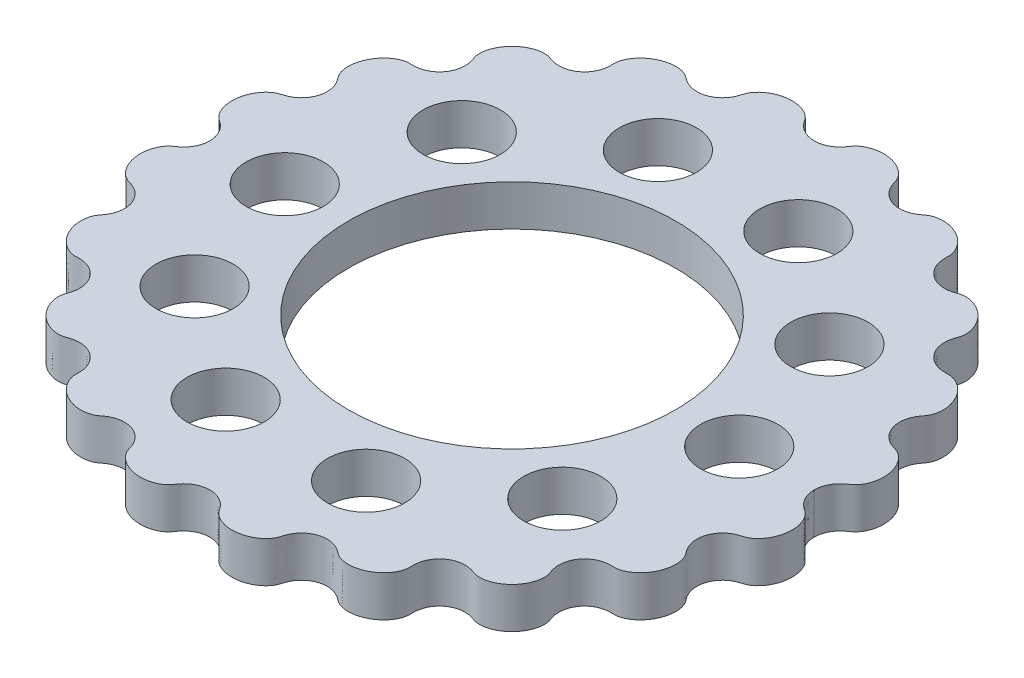
from build123d import *

# Parameters (mm, degrees)
SKETCH1_R           = 36
SKETCH1_R_2         = 8.5
BOSS_EXTRUDE1_DEPTH = 9


with BuildPart() as part:
    # Sketch1 → Boss-Extrude1 (new body)
    with BuildSketch(Plane(origin=(0, 0, 0), x_dir=(1, 0, 0), z_dir=(0, 1, 0))):
        with BuildLine():
            add(Edge.make_bspline(
                [(66.500001129, 0), (66.500001058, -0.306411604), (66.541874966, -0.881988973), (66.71785149, -1.70970182), (67.122305388, -2.64485153), (67.601319233, -3.385898988), (68.073478895, -3.930767497), (68.484626923, -4.318373717), (68.876385974, -4.631660775), (69.233666052, -4.885778583), (69.564274067, -5.103618664), (69.843214443, -5.321468288), (70.117872249, -5.581732221), (70.400827867, -5.901729461), (70.702289774, -6.32382216), (71.054596033, -6.952661744), (71.375662814, -7.747169294), (71.615376495, -8.685667354), (71.731212347, -9.758967821), (71.701410518, -10.823240788), (71.536133006, -11.860141355), (71.244225804, -12.853472523), (70.833511924, -13.788305192), (70.358839298, -14.56570152), (69.8607071, -15.191593009), (69.385303473, -15.666161002), (68.964677629, -16.012242392), (68.548124551, -16.287014605), (68.188697639, -16.471846169), (67.885284263, -16.5894738), (67.6026674, -16.678972685), (67.317739076, -16.760519952), (66.914744907, -16.885104266), (66.402737123, -17.07994391), (65.770956105, -17.391405185), (65.047003925, -17.880225456), (64.353873132, -18.533266519), (63.737773446, -19.372683616), (63.275037833, -20.335343374), (63.000837701, -21.369915681), (62.928927044, -22.453502681), (63.052813163, -23.427940267), (63.297757861, -24.251137315), (63.587039056, -24.893246766), (63.860894636, -25.371811104), (64.145161772, -25.790016395), (64.425506551, -26.15372471), (64.719695703, -26.532707796), (64.965405483, -26.968707897), (65.16448089, -27.455245279), (65.315337371, -27.986150519), (65.436916585, -28.660703608), (65.486679126, -29.479710966), (65.421096201, -30.426005667), (65.195898518, -31.477846281), (64.833514294, -32.48361594), (64.345892961, -33.427772857), (63.74361321, -34.29551734), (63.03639755, -35.071911975), (62.319416122, -35.667562159), (61.632614436, -36.102896779), (61.018606487, -36.397527171), (60.501368956, -36.585067331), (60.002736898, -36.705605486), (59.582782992, -36.754609123), (59.238659914, -36.75517943), (58.919479065, -36.745458109), (58.600187888, -36.737961835), (58.186622973, -36.744933326), (57.680555248, -36.788795144), (57.025772755, -36.903424808), (56.231100187, -37.148620477), (55.38015461, -37.568193877), (54.524775544, -38.212860592), (53.798856727, -39.016244684), (53.245744288, -39.931413343), (52.876403424, -40.932154541), (52.712876934, -41.903813432), (52.711126431, -42.801048358), (52.815319507, -43.527425125), (52.941387719, -44.03315486), (53.055590073, -44.395960805), (53.149312539, -44.668429567), (53.247939565, -44.939017776), (53.364965435, -45.291387725), (53.452192412, -45.737703364), (53.491958948, -46.257673299), (53.468644886, -46.845886624), (53.363394796, -47.556426753), (53.136734845, -48.374484506), (52.768362447, -49.246519483), (52.234936332, -50.143673486), (51.583820614, -50.970470183), (50.825006742, -51.712551368), (49.978560672, -52.346849878), (49.058219136, -52.860671942), (48.200835241, -53.193586977), (47.439728455, -53.383993333), (46.783575506, -53.471154427), (46.24340017, -53.490536996), (45.735563964, -53.453013161), (45.317452545, -53.369908695), (44.99172708, -53.265499715), (44.699608393, -53.161002724), (44.407046103, -53.057647945), (44.006263137, -52.932952789), (43.490986386, -52.811450496), (42.800133999, -52.714477617), (41.927158988, -52.709986829), (40.953037619, -52.8674568), (39.920202857, -53.248889007), (38.974122337, -53.827688413), (38.169054018, -54.570301693), (37.529920825, -55.442926772), (37.101897331, -56.344011596), (36.879347754, -57.124787466), (36.780264942, -57.759487878), (36.745430562, -58.228868202), (36.738116129, -58.595650957), (36.745630266, -58.954274161), (36.758794675, -59.304761433), (36.745284462, -59.70007659), (36.677901942, -60.135221923), (36.549281488, -60.614594814), (36.349127337, -61.129714855), (36.040546931, -61.740807466), (35.589726474, -62.423279282), (34.976854855, -63.134572527), (34.181164504, -63.833500102), (33.295605947, -64.424159937), (32.335438574, -64.896819614), (31.315952582, -65.240823512), (30.253281677, -65.444073282), (29.302808186, -65.48674432), (28.486094509, -65.414976382), (27.817189289, -65.273610755), (27.358637795, -65.126885258), (26.982811324, -64.964513373), (26.641526332, -64.779466338), (26.382523151, -64.604446335), (26.143451519, -64.417035766), (25.861696044, -64.202004392), (25.573543832, -63.995425432), (25.213648929, -63.7661345), (24.773571672, -63.53143839), (24.173339528, -63.273838015), (23.390590516, -63.045984324), (22.436442542, -62.927246339), (21.334482977, -63.005704204), (20.269322457, -63.297023261), (19.302800808, -63.777682891), (18.465112619, -64.415546161), (17.82117432, -65.12374775), (17.348875457, -65.844633027), (17.049246653, -66.473739324), (16.879558981, -66.936238465), (16.773116624, -67.278713999), (16.696957564, -67.537958402), (16.620563075, -67.797132045), (16.499910109, -68.13000156), (16.302573624, -68.520910364), (16.023587779, -68.951670595), (15.649895084, -69.406906796), (15.139193986, -69.909948084), (14.469235428, -70.425872196), (13.660692236, -70.898780689), (12.712675611, -71.294352187), (11.701994628, -71.570793286), (10.643277718, -71.71744206), (9.574432129, -71.722251848), (8.515173694, -71.581185181), (7.619740367, -71.330051494), (6.89178234, -71.02175639), (6.368073296, -70.723825833), (6.025748964, -70.488703362), (5.756441979, -70.272176118), (5.552614162, -70.086041783), (5.329274805, -69.853141606), (5.101427257, -69.562377536), (4.873847855, -69.214977588), (4.604641531, -68.839770132), (4.29459416, -68.45835192), (3.934688299, -68.081320064), (3.417413702, -67.628524246), (2.704193702, -67.1529035), (1.792081683, -66.743306058), (0.685094476, -66.494130633), (-0.46668125, -66.470382174), (-1.460634005, -66.655247766), (-2.27277114, -66.955831335), (-2.910711394, -67.297399035), (-3.378756397, -67.611091908), (-3.798269806, -67.955365866), (-4.170377951, -68.321327159), (-4.460251939, -68.657656831), (-4.682293421, -68.94855781), (-4.858086871, -69.197625947), (-4.995153, -69.399303901), (-5.139637335, -69.60756569), (-5.300663378, -69.815692329), (-5.483879701, -70.017863212), (-5.688139815, -70.212714302), (-5.959120704, -70.439264513), (-6.305281107, -70.684848193), (-6.832662081, -70.993284872), (-7.564845293, -71.311344197), (-8.469002262, -71.572281868), (-9.541810963, -71.721249267), (-10.624360619, -71.719760308), (-11.695875609, -71.572466353), (-12.71267544, -71.294352609), (-13.660692302, -70.898780413), (-14.469235338, -70.42587238), (-15.139193991, -69.909947988), (-15.649895036, -69.406906858), (-16.023587762, -68.951670569), (-16.302573588, -68.520910393), (-16.499910084, -68.130001555), (-16.620563044, -67.797132059), (-16.696957536, -67.537958408), (-16.773116594, -67.278714009), (-16.879558956, -66.93623847), (-17.04924662, -66.473739339), (-17.348875436, -65.844633027), (-17.821174284, -65.12374777), (-18.465112605, -64.415546153), (-19.302800761, -63.777682927), (-20.269322462, -63.297023229), (-21.3344829, -63.005704284), (-22.436442606, -62.927246227), (-23.390590345, -63.045984533), (-24.173339739, -63.273837703), (-24.773571205, -63.531439003), (-25.213650231, -63.766132698), (-25.573539135, -63.995431821), (-25.861714805, -64.201978754), (-26.096423255, -64.381291408), (-26.283123054, -64.526166145), (-26.480463984, -64.670880456), (-26.693581, -64.807563792), (-26.982772327, -64.96456659), (-27.35866061, -65.126854086), (-27.817177553, -65.273626754), (-28.48610211, -65.414965982), (-29.302803073, -65.486751279), (-30.253284841, -65.44406894), (-31.31595072, -65.240826032), (-32.335439646, -64.89681813), (-33.295605246, -64.424160873), (-34.181164905, -63.833499537), (-34.976854538, -63.134572942), (-35.589726622, -62.423279063), (-36.040546818, -61.740807605), (-36.349127361, -61.129714806), (-36.549281429, -60.614594879), (-36.677901938, -60.135221913), (-36.745284425, -59.700076625), (-36.758794658, -59.304761442), (-36.745630237, -58.954274186), (-36.738116108, -58.595650972), (-36.745430537, -58.228868222), (-36.780264918, -57.759487896), (-36.879347731, -57.124787485), (-37.101897309, -56.344011614), (-37.529920802, -55.442926791), (-38.169053996, -54.570301712), (-38.974122316, -53.827688433), (-39.920202836, -53.248889027), (-40.953037598, -52.867456821), (-41.927158967, -52.70998685), (-42.800133978, -52.714477639), (-43.490986365, -52.811450518), (-44.006263116, -52.932952811), (-44.407046082, -53.057647967), (-44.699608372, -53.161002746), (-44.991727058, -53.265499737), (-45.317452524, -53.369908717), (-45.735563942, -53.453013184), (-46.243400149, -53.490537019), (-46.783575484, -53.47115445), (-47.439728435, -53.383993355), (-48.200835217, -53.193587003), (-49.058219119, -52.860671963), (-49.978560645, -52.346849908), (-50.82500673, -51.712551386), (-51.583820579, -50.970470221), (-52.234936337, -50.143673491), (-52.768362385, -49.246519547), (-53.136734894, -48.374484473), (-53.363394673, -47.556426872), (-53.46864501, -46.845886524), (-53.491958674, -46.257673553), (-53.452192822, -45.737703011), (-53.364964723, -45.291388368), (-53.247940118, -44.939017298), (-53.149315765, -44.668426717), (-53.055570755, -44.395977946), (-52.969692354, -44.122896947), (-52.883657782, -43.801782329), (-52.78827759, -43.338670594), (-52.711291109, -42.706581466), (-52.712889665, -41.903802155), (-52.876396003, -40.932161135), (-53.245748679, -39.931409464), (-53.798854054, -39.016247069), (-54.524777207, -38.212859131), (-55.380153424, -37.568194944), (-56.231100935, -37.14861983), (-57.02577227, -36.903425254), (-57.680555541, -36.788794902), (-58.186622744, -36.744933547), (-58.600187985, -36.737961767), (-58.919479015, -36.745458171), (-59.238659914, -36.755179448), (-59.582782971, -36.75460916), (-60.002736889, -36.705605512), (-60.50136894, -36.585067364), (-61.018606475, -36.3975272), (-61.632614423, -36.10289681), (-62.31941611, -35.66756219), (-63.036397537, -35.071912007), (-63.743613199, -34.295517372), (-64.34589295, -33.427772889), (-64.833514283, -32.483615972), (-65.195898508, -31.477846314), (-65.421096191, -30.4260057), (-65.486679116, -29.479710998), (-65.436916576, -28.66070364), (-65.315337362, -27.986150552), (-65.164480881, -27.455245311), (-64.965405475, -26.968707929), (-64.719695695, -26.532707828), (-64.425506543, -26.153724742), (-64.145161764, -25.790016427), (-63.860894629, -25.371811135), (-63.587039049, -24.893246797), (-63.297757855, -24.251137347), (-63.052813157, -23.427940298), (-62.928927038, -22.453502713), (-63.000837696, -21.369915712), (-63.275037828, -20.335343405), (-63.737773441, -19.372683648), (-64.353873128, -18.533266551), (-65.047003922, -17.880225489), (-65.770956102, -17.391405218), (-66.402737119, -17.079943943), (-66.914744904, -16.885104299), (-67.317739073, -16.760519985), (-67.602667397, -16.678972718), (-67.88528426, -16.589473833), (-68.188697636, -16.471846203), (-68.548124548, -16.287014639), (-68.964677627, -16.012242426), (-69.385303471, -15.666161036), (-69.860707098, -15.191593044), (-70.358839296, -14.565701555), (-70.833511922, -13.788305227), (-71.244225803, -12.853472558), (-71.536133006, -11.860141391), (-71.701410518, -10.823240824), (-71.731212347, -9.758967856), (-71.615376496, -8.685667389), (-71.375662816, -7.747169329), (-71.054596035, -6.952661779), (-70.702289775, -6.323822195), (-70.400827869, -5.901729497), (-70.117872252, -5.581732255), (-69.843214446, -5.321468323), (-69.564274069, -5.103618697), (-69.233666056, -4.885778622), (-68.876385975, -4.631660802), (-68.48462693, -4.318373763), (-68.073478891, -3.930767512), (-67.601319246, -3.385899048), (-67.122305378, -2.644851524), (-66.717851511, -1.709701904), (-66.541874944, -0.881988919), (-66.500001064, -0.306411605), (-66.500001142, 0)],
                knots=[0.107227573, 0.107227573, 0.107227573, 0.107227573, 0.107227573, 0.110899605, 0.114125262, 0.117297955, 0.119365342, 0.12143273, 0.122745926, 0.124059122, 0.125372319, 0.126685515, 0.127489642, 0.128293769, 0.129902022, 0.131796763, 0.133691503, 0.136915486, 0.14013947, 0.143363023, 0.146586577, 0.149636972, 0.152687367, 0.155737512, 0.158787658, 0.160518035, 0.162248411, 0.16377611, 0.165303808, 0.166487656, 0.16707958, 0.167671505, 0.168855353, 0.170039201, 0.172133935, 0.174228668, 0.177277837, 0.180469506, 0.183482711, 0.186636923, 0.190006747, 0.193215352, 0.196415061, 0.198338344, 0.200261626, 0.201638223, 0.203014821, 0.204391418, 0.205768015, 0.20737848, 0.208988945, 0.210678965, 0.212368986, 0.215581346, 0.218793706, 0.222006092, 0.225218479, 0.228355258, 0.231492038, 0.234628768, 0.237765499, 0.239487542, 0.241209585, 0.242778062, 0.244346538, 0.245622308, 0.246260192, 0.246898077, 0.248173846, 0.249449616, 0.251214165, 0.252978714, 0.256127597, 0.259382101, 0.262517266, 0.265738303, 0.269026705, 0.272116988, 0.275225209, 0.2774808, 0.279736391, 0.280887314, 0.281462776, 0.282038237, 0.28318916, 0.284340084, 0.285905879, 0.287471675, 0.289425665, 0.291379655, 0.294497435, 0.297615215, 0.300732841, 0.303850467, 0.307074425, 0.310298382, 0.31337072, 0.316443057, 0.318059604, 0.319676151, 0.321292619, 0.322909086, 0.324148554, 0.324768288, 0.325388022, 0.32662749, 0.327866958, 0.329795802, 0.331724645, 0.334971979, 0.338289395, 0.341547885, 0.344835886, 0.34817973, 0.35133024, 0.354430803, 0.35672383, 0.357870343, 0.359016857, 0.360067543, 0.361118229, 0.362168914, 0.3632196, 0.364800497, 0.366381395, 0.368105721, 0.369830048, 0.372993142, 0.376156236, 0.379319389, 0.382482541, 0.385713434, 0.388944326, 0.392175014, 0.395405702, 0.397072955, 0.398740208, 0.400355996, 0.401163891, 0.401971785, 0.403387693, 0.404095647, 0.404803601, 0.40621951, 0.407635418, 0.409204663, 0.410773909, 0.414037141, 0.417372109, 0.420655125, 0.423928266, 0.427187498, 0.430226971, 0.433200462, 0.435339705, 0.437478948, 0.43855829, 0.43909796, 0.439637631, 0.440716972, 0.441796314, 0.443334185, 0.444872057, 0.446855976, 0.448839896, 0.451908577, 0.454977259, 0.45804593, 0.461114601, 0.464431853, 0.467749105, 0.470814309, 0.473879513, 0.475538589, 0.477197664, 0.478024147, 0.47885063, 0.479677113, 0.480503596, 0.481886651, 0.483269706, 0.48465276, 0.486035815, 0.487772004, 0.489508194, 0.492878492, 0.496270276, 0.499675403, 0.503014057, 0.506592321, 0.50830093, 0.51000954, 0.51167164, 0.513333741, 0.51479501, 0.51625628, 0.516986914, 0.517717549, 0.518448184, 0.519178819, 0.520023889, 0.52086896, 0.52171403, 0.522559101, 0.524253928, 0.525948755, 0.529023994, 0.532099233, 0.535492308, 0.538885383, 0.541954054, 0.545022725, 0.548091406, 0.551160088, 0.553144007, 0.555127927, 0.556665798, 0.55820367, 0.559283011, 0.560362353, 0.560902023, 0.561441694, 0.562521035, 0.564660278, 0.566799521, 0.569773013, 0.572812485, 0.576071718, 0.579344859, 0.582627875, 0.585962843, 0.589226075, 0.59079532, 0.592364566, 0.593780474, 0.595196382, 0.595904336, 0.59661229, 0.597320244, 0.598028198, 0.598836093, 0.599643987, 0.601259776, 0.602927029, 0.604594282, 0.60782497, 0.611055658, 0.61428655, 0.617517442, 0.620680595, 0.623843748, 0.627006842, 0.630169936, 0.631894262, 0.633618589, 0.635199486, 0.636780383, 0.637831069, 0.638881755, 0.639932441, 0.640983127, 0.64212964, 0.643276154, 0.645569181, 0.648669744, 0.651820253, 0.655164097, 0.658452098, 0.661710588, 0.665028004, 0.668275338, 0.670204182, 0.672133025, 0.673372493, 0.674611961, 0.675231696, 0.67585143, 0.677090898, 0.678707365, 0.680323832, 0.681940379, 0.683556927, 0.686629264, 0.689701601, 0.692925559, 0.696149516, 0.699267143, 0.702384769, 0.705502549, 0.708620329, 0.710574319, 0.712528308, 0.714094104, 0.7156599, 0.716810823, 0.717961746, 0.718537208, 0.719112669, 0.720263592, 0.721391388, 0.722519183, 0.724774775, 0.727882996, 0.730973278, 0.734261681, 0.737482718, 0.740617883, 0.743872386, 0.747021269, 0.748785818, 0.750550368, 0.751826137, 0.753101906, 0.753739791, 0.754377676, 0.755653445, 0.757221922, 0.758790398, 0.760512441, 0.762234484, 0.765371215, 0.768507946, 0.771644725, 0.774781505, 0.777993891, 0.781206278, 0.784418638, 0.787630998, 0.789321018, 0.791011039, 0.792621503, 0.794231968, 0.795608565, 0.796985163, 0.79836176, 0.799738358, 0.80166164, 0.803584922, 0.806784631, 0.809993236, 0.81336306, 0.816517272, 0.819530478, 0.822722147, 0.825771315, 0.827866049, 0.829960782, 0.831144631, 0.832328479, 0.832920403, 0.833512327, 0.834696176, 0.836223874, 0.837751572, 0.839481949, 0.841212326, 0.844262471, 0.847312617, 0.850363012, 0.853413407, 0.85663696, 0.859860514, 0.863084497, 0.866308481, 0.868203221, 0.870097961, 0.871706215, 0.872510342, 0.873314469, 0.874627665, 0.875940861, 0.877254057, 0.878567254, 0.880634641, 0.882702029, 0.885874721, 0.889100378, 0.892772411, 0.892772411, 0.892772411, 0.892772411, 0.892772411], degree=4))
            add(Edge.make_bspline(
                [(66.500001129, 0), (66.500001049, 0.306411644), (66.541874949, 0.881989055), (66.717851474, 1.709701945), (67.122305388, 2.644851692), (67.601319233, 3.38589915), (68.073478895, 3.930767659), (68.484626923, 4.318373879), (68.876385974, 4.631660937), (69.233666052, 4.885778745), (69.564274067, 5.103618826), (69.843214443, 5.32146845), (70.117872249, 5.581732383), (70.400827867, 5.901729623), (70.702289774, 6.323822322), (71.054596033, 6.952661906), (71.375662814, 7.747169456), (71.615376495, 8.685667516), (71.731212347, 9.758967983), (71.701410518, 10.82324095), (71.536133006, 11.860141517), (71.244225804, 12.853472685), (70.833511924, 13.788305354), (70.358839298, 14.565701682), (69.8607071, 15.191593171), (69.385303473, 15.666161164), (68.964677629, 16.012242554), (68.548124551, 16.287014767), (68.188697639, 16.471846331), (67.885284263, 16.589473962), (67.6026674, 16.678972847), (67.317739076, 16.760520114), (66.914744907, 16.885104428), (66.402737123, 17.079944072), (65.770956105, 17.391405347), (65.047003925, 17.880225618), (64.353873132, 18.533266681), (63.737773446, 19.372683778), (63.275037833, 20.335343536), (63.000837701, 21.369915843), (62.928927044, 22.453502843), (63.052813163, 23.427940429), (63.297757861, 24.251137477), (63.587039056, 24.893246928), (63.860894636, 25.371811266), (64.145161771, 25.790016557), (64.425506551, 26.153724872), (64.719695703, 26.532707958), (64.965405483, 26.968708059), (65.16448089, 27.455245441), (65.315337371, 27.986150681), (65.436916585, 28.66070377), (65.486679126, 29.479711128), (65.421096201, 30.426005829), (65.195898518, 31.477846443), (64.833514294, 32.483616102), (64.345892961, 33.427773019), (63.74361321, 34.295517502), (63.03639755, 35.071912137), (62.319416122, 35.667562321), (61.632614436, 36.102896941), (61.018606487, 36.397527333), (60.501368956, 36.585067493), (60.002736898, 36.705605648), (59.582782992, 36.754609285), (59.238659914, 36.755179592), (58.919479065, 36.745458271), (58.600187888, 36.737961997), (58.186622973, 36.744933488), (57.680555248, 36.788795306), (57.025772755, 36.90342497), (56.231100187, 37.148620639), (55.38015461, 37.568194039), (54.524775544, 38.212860754), (53.798856727, 39.016244846), (53.245744288, 39.931413505), (52.876403424, 40.932154703), (52.712876934, 41.903813594), (52.711126431, 42.80104852), (52.815319507, 43.527425287), (52.941387719, 44.033155022), (53.055590072, 44.395960967), (53.149312539, 44.668429729), (53.247939565, 44.939017938), (53.364965435, 45.291387887), (53.452192412, 45.737703526), (53.491958948, 46.257673461), (53.468644886, 46.845886786), (53.363394796, 47.556426915), (53.136734845, 48.374484668), (52.768362447, 49.246519645), (52.234936332, 50.143673648), (51.583820614, 50.970470345), (50.825006742, 51.71255153), (49.978560672, 52.34685004), (49.058219136, 52.860672104), (48.200835241, 53.193587139), (47.439728455, 53.383993495), (46.783575506, 53.471154589), (46.24340017, 53.490537158), (45.735563964, 53.453013323), (45.317452545, 53.369908857), (44.99172708, 53.265499877), (44.699608393, 53.161002886), (44.407046103, 53.057648107), (44.006263137, 52.932952951), (43.490986386, 52.811450658), (42.800133999, 52.714477779), (41.927158988, 52.709986991), (40.953037619, 52.867456962), (39.920202857, 53.248889169), (38.974122337, 53.827688575), (38.169054018, 54.570301855), (37.529920825, 55.442926934), (37.101897331, 56.344011758), (36.879347754, 57.124787628), (36.780264941, 57.75948804), (36.745430562, 58.228868364), (36.738116129, 58.595651119), (36.745630266, 58.954274323), (36.758794675, 59.304761595), (36.745284462, 59.700076752), (36.677901942, 60.135222085), (36.549281488, 60.614594976), (36.349127337, 61.129715017), (36.040546931, 61.740807628), (35.589726474, 62.423279444), (34.976854855, 63.134572689), (34.181164504, 63.833500264), (33.295605946, 64.424160099), (32.335438574, 64.896819776), (31.315952582, 65.240823674), (30.253281677, 65.444073444), (29.302808186, 65.486744482), (28.486094509, 65.414976544), (27.817189289, 65.273610917), (27.358637795, 65.12688542), (26.982811324, 64.964513535), (26.641526332, 64.7794665), (26.382523151, 64.604446497), (26.143451519, 64.417035928), (25.861696044, 64.202004554), (25.573543832, 63.995425594), (25.213648929, 63.766134662), (24.773571672, 63.531438552), (24.173339528, 63.273838177), (23.390590516, 63.045984486), (22.436442542, 62.927246501), (21.334482977, 63.005704366), (20.269322457, 63.297023423), (19.302800807, 63.777683053), (18.465112619, 64.415546323), (17.82117432, 65.123747912), (17.348875457, 65.844633189), (17.049246653, 66.473739486), (16.879558981, 66.936238627), (16.773116624, 67.278714161), (16.696957564, 67.537958564), (16.620563075, 67.797132207), (16.499910109, 68.130001722), (16.302573624, 68.520910526), (16.023587779, 68.951670757), (15.649895084, 69.406906958), (15.139193986, 69.909948246), (14.469235428, 70.425872358), (13.660692236, 70.898780851), (12.712675611, 71.294352349), (11.701994627, 71.570793448), (10.643277718, 71.717442222), (9.574432129, 71.72225201), (8.515173694, 71.581185343), (7.619740367, 71.330051656), (6.891782339, 71.021756552), (6.368073296, 70.723825995), (6.025748964, 70.488703524), (5.756441979, 70.27217628), (5.552614162, 70.086041945), (5.329274805, 69.853141768), (5.101427257, 69.562377698), (4.873847855, 69.21497775), (4.604641531, 68.839770294), (4.29459416, 68.458352082), (3.934688299, 68.081320226), (3.417413702, 67.628524408), (2.704193702, 67.152903662), (1.792081683, 66.74330622), (0.685094476, 66.494130795), (-0.46668125, 66.470382336), (-1.460634005, 66.655247928), (-2.27277114, 66.955831497), (-2.910711394, 67.297399197), (-3.378756397, 67.61109207), (-3.798269806, 67.955366028), (-4.170377951, 68.321327321), (-4.460251939, 68.657656993), (-4.682293421, 68.948557972), (-4.858086871, 69.197626109), (-4.995153, 69.399304063), (-5.139637335, 69.607565852), (-5.300663378, 69.815692491), (-5.483879701, 70.017863374), (-5.688139815, 70.212714464), (-5.959120704, 70.439264675), (-6.305281107, 70.684848355), (-6.832662081, 70.993285034), (-7.564845293, 71.311344359), (-8.469002262, 71.57228203), (-9.541810963, 71.721249429), (-10.624360619, 71.71976047), (-11.695875609, 71.572466515), (-12.71267544, 71.294352771), (-13.660692302, 70.898780575), (-14.469235338, 70.425872542), (-15.139193991, 69.90994815), (-15.649895036, 69.40690702), (-16.023587762, 68.951670731), (-16.302573588, 68.520910555), (-16.499910084, 68.130001717), (-16.620563044, 67.797132221), (-16.696957536, 67.53795857), (-16.773116594, 67.278714171), (-16.879558956, 66.936238632), (-17.04924662, 66.473739501), (-17.348875436, 65.844633189), (-17.821174284, 65.123747932), (-18.465112605, 64.415546315), (-19.302800761, 63.777683089), (-20.269322462, 63.297023391), (-21.3344829, 63.005704446), (-22.436442606, 62.927246389), (-23.390590345, 63.045984695), (-24.173339739, 63.273837865), (-24.773571205, 63.531439165), (-25.213650231, 63.76613286), (-25.573539135, 63.995431983), (-25.861714805, 64.201978916), (-26.096423255, 64.38129157), (-26.283123054, 64.526166307), (-26.480463984, 64.670880618), (-26.693581, 64.807563954), (-26.982772327, 64.964566752), (-27.35866061, 65.126854247), (-27.817177553, 65.273626916), (-28.48610211, 65.414966144), (-29.302803073, 65.486751441), (-30.253284841, 65.444069102), (-31.31595072, 65.240826194), (-32.335439646, 64.896818292), (-33.295605246, 64.424161035), (-34.181164905, 63.833499699), (-34.976854538, 63.134573104), (-35.589726622, 62.423279225), (-36.040546818, 61.740807767), (-36.349127361, 61.129714968), (-36.549281429, 60.614595041), (-36.677901938, 60.135222074), (-36.745284425, 59.700076787), (-36.758794658, 59.304761604), (-36.745630237, 58.954274348), (-36.738116108, 58.595651134), (-36.745430537, 58.228868384), (-36.780264919, 57.759488058), (-36.879347731, 57.124787647), (-37.101897309, 56.344011776), (-37.529920802, 55.442926953), (-38.169053996, 54.570301874), (-38.974122316, 53.827688595), (-39.920202836, 53.248889189), (-40.953037598, 52.867456983), (-41.927158967, 52.709987012), (-42.800133978, 52.7144778), (-43.490986365, 52.81145068), (-44.006263116, 52.932952973), (-44.407046082, 53.057648129), (-44.699608372, 53.161002908), (-44.991727058, 53.265499899), (-45.317452524, 53.369908879), (-45.735563942, 53.453013346), (-46.243400149, 53.490537181), (-46.783575484, 53.471154612), (-47.439728435, 53.383993517), (-48.200835217, 53.193587165), (-49.058219119, 52.860672125), (-49.978560645, 52.34685007), (-50.82500673, 51.712551548), (-51.583820579, 50.970470383), (-52.234936337, 50.143673653), (-52.768362385, 49.246519709), (-53.136734894, 48.374484635), (-53.363394673, 47.556427034), (-53.46864501, 46.845886686), (-53.491958674, 46.257673715), (-53.452192822, 45.737703173), (-53.364964723, 45.29138853), (-53.247940118, 44.93901746), (-53.149315765, 44.668426879), (-53.055570755, 44.395978107), (-52.969692354, 44.122897109), (-52.883657782, 43.801782491), (-52.78827759, 43.338670756), (-52.711291109, 42.706581628), (-52.712889665, 41.903802317), (-52.876396003, 40.932161297), (-53.245748679, 39.931409626), (-53.798854054, 39.016247231), (-54.524777207, 38.212859293), (-55.380153424, 37.568195106), (-56.231100935, 37.148619992), (-57.02577227, 36.903425416), (-57.680555541, 36.788795064), (-58.186622744, 36.744933709), (-58.600187985, 36.737961929), (-58.919479015, 36.745458333), (-59.238659914, 36.75517961), (-59.582782971, 36.754609322), (-60.002736889, 36.705605674), (-60.50136894, 36.585067525), (-61.018606475, 36.397527362), (-61.632614423, 36.102896972), (-62.31941611, 35.667562352), (-63.036397537, 35.071912169), (-63.743613199, 34.295517534), (-64.34589295, 33.427773051), (-64.833514283, 32.483616134), (-65.195898508, 31.477846476), (-65.421096191, 30.426005862), (-65.486679116, 29.47971116), (-65.436916576, 28.660703802), (-65.315337362, 27.986150714), (-65.164480881, 27.455245473), (-64.965405475, 26.968708091), (-64.719695695, 26.53270799), (-64.425506543, 26.153724904), (-64.145161764, 25.790016589), (-63.860894629, 25.371811297), (-63.587039049, 24.893246959), (-63.297757855, 24.251137509), (-63.052813157, 23.42794046), (-62.928927038, 22.453502875), (-63.000837696, 21.369915874), (-63.275037828, 20.335343567), (-63.737773441, 19.37268381), (-64.353873128, 18.533266713), (-65.047003922, 17.880225651), (-65.770956102, 17.39140538), (-66.402737119, 17.079944105), (-66.914744904, 16.885104461), (-67.317739073, 16.760520147), (-67.602667397, 16.67897288), (-67.88528426, 16.589473995), (-68.188697636, 16.471846364), (-68.548124548, 16.287014801), (-68.964677627, 16.012242588), (-69.385303471, 15.666161198), (-69.860707098, 15.191593206), (-70.358839296, 14.565701717), (-70.833511922, 13.788305389), (-71.244225803, 12.85347272), (-71.536133006, 11.860141553), (-71.701410518, 10.823240985), (-71.731212347, 9.758968018), (-71.615376496, 8.685667551), (-71.375662816, 7.747169491), (-71.054596035, 6.952661941), (-70.702289775, 6.323822357), (-70.400827869, 5.901729659), (-70.117872252, 5.581732417), (-69.843214446, 5.321468485), (-69.564274069, 5.103618859), (-69.233666056, 4.885778784), (-68.876385975, 4.631660964), (-68.48462693, 4.318373925), (-68.073478891, 3.930767674), (-67.601319246, 3.38589921), (-67.122305378, 2.644851686), (-66.717851495, 1.709702029), (-66.541874927, 0.881989001), (-66.500001055, 0.306411645), (-66.500001142, 0)],
                knots=[0.107227572, 0.107227572, 0.107227572, 0.107227572, 0.107227572, 0.110899605, 0.114125262, 0.117297955, 0.119365342, 0.12143273, 0.122745926, 0.124059122, 0.125372319, 0.126685515, 0.127489642, 0.128293769, 0.129902022, 0.131796763, 0.133691503, 0.136915486, 0.14013947, 0.143363023, 0.146586577, 0.149636972, 0.152687367, 0.155737512, 0.158787658, 0.160518035, 0.162248411, 0.16377611, 0.165303808, 0.166487656, 0.16707958, 0.167671505, 0.168855353, 0.170039201, 0.172133935, 0.174228668, 0.177277837, 0.180469506, 0.183482711, 0.186636923, 0.190006747, 0.193215352, 0.196415061, 0.198338344, 0.200261626, 0.201638223, 0.203014821, 0.204391418, 0.205768015, 0.20737848, 0.208988945, 0.210678965, 0.212368986, 0.215581346, 0.218793706, 0.222006092, 0.225218479, 0.228355258, 0.231492038, 0.234628768, 0.237765499, 0.239487542, 0.241209585, 0.242778062, 0.244346538, 0.245622308, 0.246260192, 0.246898077, 0.248173846, 0.249449616, 0.251214165, 0.252978714, 0.256127597, 0.259382101, 0.262517266, 0.265738303, 0.269026705, 0.272116988, 0.275225209, 0.2774808, 0.279736391, 0.280887314, 0.281462776, 0.282038237, 0.28318916, 0.284340084, 0.285905879, 0.287471675, 0.289425665, 0.291379655, 0.294497435, 0.297615215, 0.300732841, 0.303850467, 0.307074425, 0.310298382, 0.31337072, 0.316443057, 0.318059604, 0.319676151, 0.321292619, 0.322909086, 0.324148554, 0.324768288, 0.325388022, 0.32662749, 0.327866958, 0.329795802, 0.331724645, 0.334971979, 0.338289395, 0.341547885, 0.344835886, 0.34817973, 0.35133024, 0.354430803, 0.35672383, 0.357870343, 0.359016857, 0.360067543, 0.361118229, 0.362168914, 0.3632196, 0.364800497, 0.366381395, 0.368105721, 0.369830048, 0.372993142, 0.376156236, 0.379319389, 0.382482541, 0.385713434, 0.388944326, 0.392175014, 0.395405702, 0.397072955, 0.398740208, 0.400355996, 0.401163891, 0.401971785, 0.403387693, 0.404095647, 0.404803601, 0.40621951, 0.407635418, 0.409204663, 0.410773909, 0.414037141, 0.417372109, 0.420655125, 0.423928266, 0.427187498, 0.430226971, 0.433200462, 0.435339705, 0.437478948, 0.43855829, 0.43909796, 0.439637631, 0.440716972, 0.441796314, 0.443334185, 0.444872057, 0.446855976, 0.448839896, 0.451908577, 0.454977259, 0.45804593, 0.461114601, 0.464431853, 0.467749105, 0.470814309, 0.473879513, 0.475538589, 0.477197664, 0.478024147, 0.47885063, 0.479677113, 0.480503596, 0.481886651, 0.483269706, 0.48465276, 0.486035815, 0.487772004, 0.489508194, 0.492878492, 0.496270276, 0.499675403, 0.503014057, 0.506592321, 0.50830093, 0.51000954, 0.51167164, 0.513333741, 0.51479501, 0.51625628, 0.516986914, 0.517717549, 0.518448184, 0.519178819, 0.520023889, 0.52086896, 0.52171403, 0.522559101, 0.524253928, 0.525948755, 0.529023994, 0.532099233, 0.535492308, 0.538885383, 0.541954054, 0.545022725, 0.548091406, 0.551160088, 0.553144007, 0.555127927, 0.556665798, 0.55820367, 0.559283011, 0.560362353, 0.560902023, 0.561441694, 0.562521035, 0.564660278, 0.566799521, 0.569773013, 0.572812485, 0.576071718, 0.579344859, 0.582627875, 0.585962843, 0.589226075, 0.59079532, 0.592364566, 0.593780474, 0.595196382, 0.595904336, 0.59661229, 0.597320244, 0.598028198, 0.598836093, 0.599643987, 0.601259776, 0.602927029, 0.604594282, 0.60782497, 0.611055658, 0.61428655, 0.617517442, 0.620680595, 0.623843748, 0.627006842, 0.630169936, 0.631894262, 0.633618589, 0.635199486, 0.636780383, 0.637831069, 0.638881755, 0.639932441, 0.640983127, 0.64212964, 0.643276154, 0.645569181, 0.648669744, 0.651820253, 0.655164097, 0.658452098, 0.661710588, 0.665028004, 0.668275338, 0.670204182, 0.672133025, 0.673372493, 0.674611961, 0.675231696, 0.67585143, 0.677090898, 0.678707365, 0.680323832, 0.681940379, 0.683556927, 0.686629264, 0.689701601, 0.692925559, 0.696149516, 0.699267143, 0.702384769, 0.705502549, 0.708620329, 0.710574319, 0.712528308, 0.714094104, 0.7156599, 0.716810823, 0.717961746, 0.718537208, 0.719112669, 0.720263592, 0.721391388, 0.722519183, 0.724774775, 0.727882996, 0.730973278, 0.734261681, 0.737482718, 0.740617883, 0.743872386, 0.747021269, 0.748785818, 0.750550368, 0.751826137, 0.753101906, 0.753739791, 0.754377676, 0.755653445, 0.757221922, 0.758790398, 0.760512441, 0.762234484, 0.765371215, 0.768507946, 0.771644725, 0.774781505, 0.777993891, 0.781206278, 0.784418638, 0.787630998, 0.789321018, 0.791011039, 0.792621503, 0.794231968, 0.795608565, 0.796985163, 0.79836176, 0.799738358, 0.80166164, 0.803584922, 0.806784631, 0.809993236, 0.81336306, 0.816517272, 0.819530478, 0.822722147, 0.825771315, 0.827866049, 0.829960782, 0.831144631, 0.832328479, 0.832920403, 0.833512327, 0.834696176, 0.836223874, 0.837751572, 0.839481949, 0.841212326, 0.844262471, 0.847312617, 0.850363012, 0.853413407, 0.85663696, 0.859860514, 0.863084497, 0.866308481, 0.868203221, 0.870097961, 0.871706215, 0.872510342, 0.873314469, 0.874627665, 0.875940861, 0.877254057, 0.878567254, 0.880634641, 0.882702029, 0.885874721, 0.889100378, 0.892772411, 0.892772411, 0.892772411, 0.892772411, 0.892772411], degree=4))
        make_face()
        with Locations(Location((0, 0, 0), (0, 0, 270))):
            Circle(SKETCH1_R, mode=Mode.SUBTRACT)
        with Locations(Location((50, 0, 0), (0, 0, 270))):
            Circle(SKETCH1_R_2, mode=Mode.SUBTRACT)
        with Locations(Location((40.450849719, -29.389262615, 0), (0, 0, 270))):
            Circle(SKETCH1_R_2, mode=Mode.SUBTRACT)
        with Locations(Location((15.450849719, -47.552825815, 0), (0, 0, 270))):
            Circle(SKETCH1_R_2, mode=Mode.SUBTRACT)
        with Locations(Location((-15.450849719, -47.552825815, 0), (0, 0, 270))):
            Circle(SKETCH1_R_2, mode=Mode.SUBTRACT)
        with Locations(Location((-40.450849719, -29.389262615, 0), (0, 0, 270))):
            Circle(SKETCH1_R_2, mode=Mode.SUBTRACT)
        with Locations(Location((-50, 0, 0), (0, 0, 270))):
            Circle(SKETCH1_R_2, mode=Mode.SUBTRACT)
        with Locations(Location((-40.450849719, 29.389262615, 0), (0, 0, 270))):
            Circle(SKETCH1_R_2, mode=Mode.SUBTRACT)
        with Locations(Location((-15.450849719, 47.552825815, 0), (0, 0, 270))):
            Circle(SKETCH1_R_2, mode=Mode.SUBTRACT)
        with Locations(Location((15.450849719, 47.552825815, 0), (0, 0, 270))):
            Circle(SKETCH1_R_2, mode=Mode.SUBTRACT)
        with Locations(Location((40.450849719, 29.389262615, 0), (0, 0, 270))):
            Circle(SKETCH1_R_2, mode=Mode.SUBTRACT)
    extrude(amount=BOSS_EXTRUDE1_DEPTH)


solid = part.part
